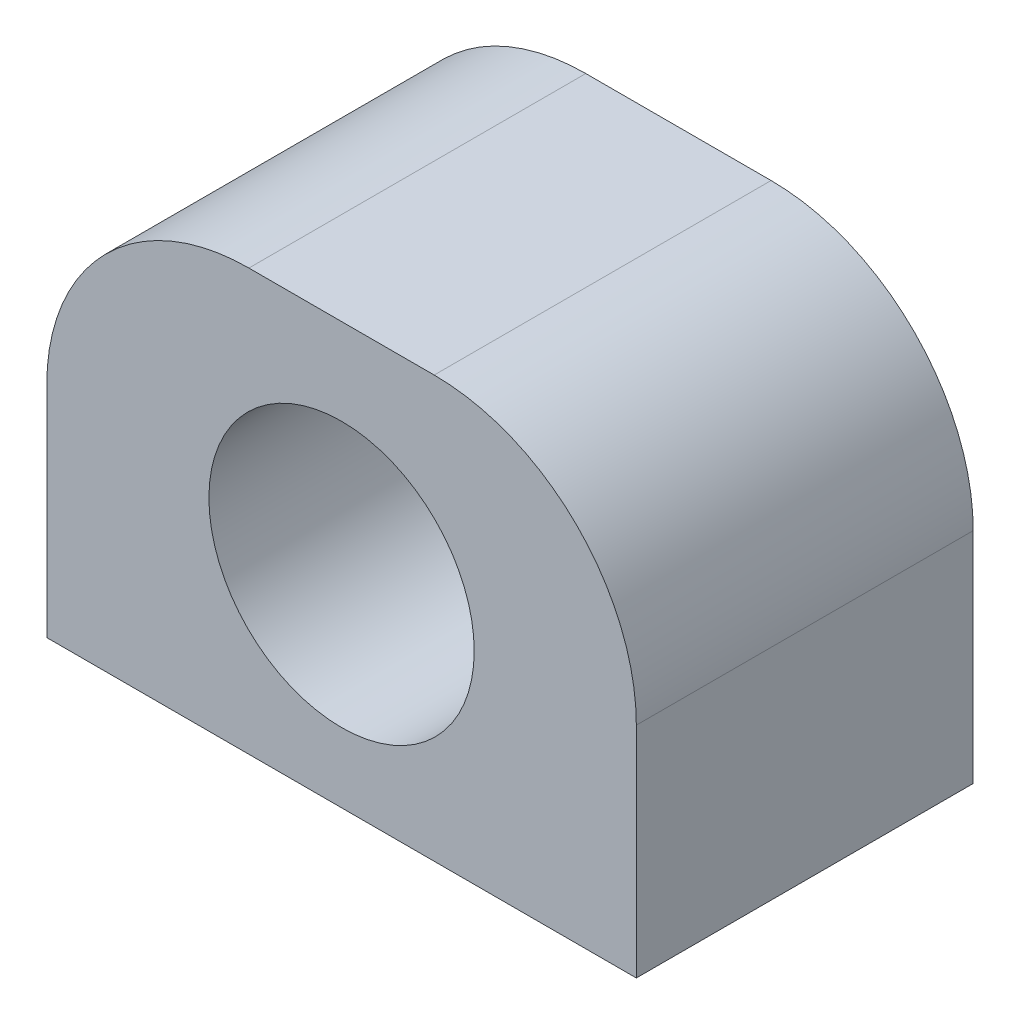
from build123d import *

# Parameters (mm, degrees)
SKETCH1_W           = 35
SKETCH1_H           = 20
BOSS_EXTRUDE1_DEPTH = 25
SKETCH2_R           = 7.875
CUT_EXTRUDE1_DEPTH  = 21
SKETCH3_R           = 1.75
CUT_EXTRUDE2_DEPTH  = 10
FILLET1_R           = 12


with BuildPart() as part:
    # Sketch1 → Boss-Extrude1 (new body)
    with BuildSketch(Plane(origin=(0, 0, 0), x_dir=(1, 0, 0), z_dir=(0, 1, 0))):
        with Locations((1.164675851, -0.855170824)):
            Rectangle(SKETCH1_W, SKETCH1_H)
    extrude(amount=BOSS_EXTRUDE1_DEPTH)

    # Sketch2 → Cut-Extrude1 (cut, through all)
    with BuildSketch(Plane.XY.offset(10.855170824)):
        with Locations((1.164675851, 12)):
            Circle(SKETCH2_R)
    extrude(amount=-CUT_EXTRUDE1_DEPTH, mode=Mode.SUBTRACT)

    # Sketch3 → Cut-Extrude2 (cut)
    with BuildSketch(Plane.XZ):
        with Locations((-8.335324149, 0.855170824)):
            Circle(SKETCH3_R)
        with Locations((10.664675851, 0.855170824)):
            Circle(SKETCH3_R)
    extrude(amount=-CUT_EXTRUDE2_DEPTH, mode=Mode.SUBTRACT)

    # Fillet1
    fillet1_edges = [part.edges().sort_by_distance(p)[0] for p in [
        (18.664675851, 25, 0.855170824),
        (-16.335324149, 25, 0.855170824),
    ]]
    fillet(fillet1_edges, radius=FILLET1_R)


solid = part.part
